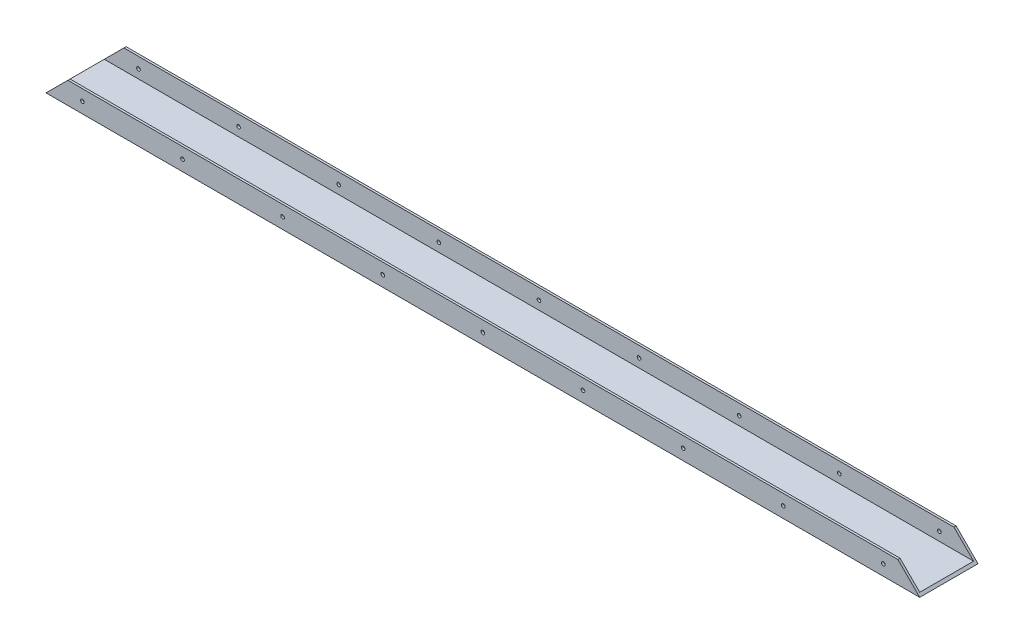
from build123d import *

# Parameters (mm, degrees)
SALIENTE_EXTRUIR1_DEPTH = 600
CROQUIS2_R              = 1.25
CORTAR_EXTRUIR1_DEPTH   = 41


with BuildPart() as part:
    # Croquis1 → Saliente-Extruir1 (new body)
    with BuildSketch(Plane(origin=(0, 0, 0), x_dir=(0, 0, -1), z_dir=(1, 0, 0))):
        Polygon((-20, 0), (20, 0), (20, 15), (18.5, 15), (18.5, 1.5), (-18.5, 1.5), (-18.5, 15), (-20, 15), align=None)
    extrude(amount=SALIENTE_EXTRUIR1_DEPTH)

    # Croquis2 → Cortar-Extruir1 (cut, through all)
    with BuildSketch(Plane(origin=(0, 0, -20), x_dir=(-1, 0, 0), z_dir=(0, 0, -1))):
        with Locations((-25, 7.5)):
            Circle(CROQUIS2_R)
        with Locations((-93.75, 7.5)):
            Circle(CROQUIS2_R)
        with Locations((-162.5, 7.5)):
            Circle(CROQUIS2_R)
        with Locations((-231.25, 7.5)):
            Circle(CROQUIS2_R)
        with Locations((-368.75, 7.5)):
            Circle(CROQUIS2_R)
        with Locations((-437.5, 7.5)):
            Circle(CROQUIS2_R)
        with Locations((-506.25, 7.5)):
            Circle(CROQUIS2_R)
        with Locations((-575, 7.5)):
            Circle(CROQUIS2_R)
        with Locations((-300, 7.5)):
            Circle(CROQUIS2_R)
        Polygon((-600, 15), (-585, 15), (-600, 0), align=None)
        Polygon((0, 15), (-15, 15), (0, 0), align=None)
    extrude(amount=-CORTAR_EXTRUIR1_DEPTH, mode=Mode.SUBTRACT)


solid = part.part
